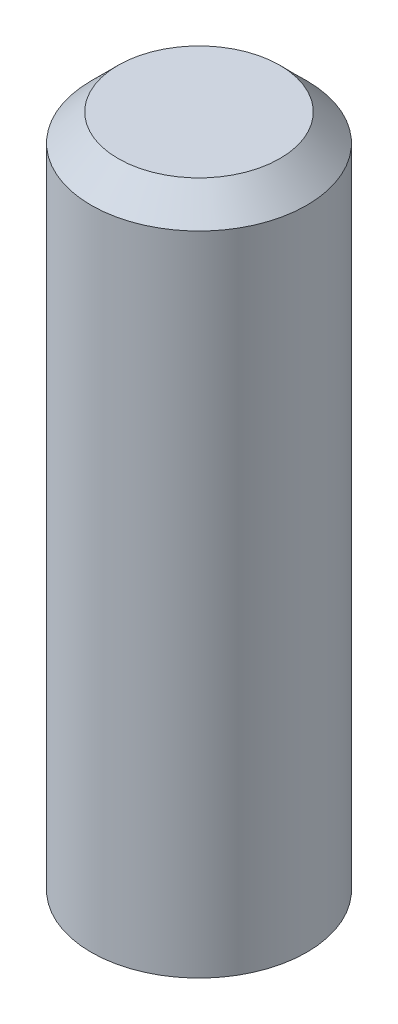
from build123d import *

# Parameters (mm, degrees)
SKETCH1_R             = 4
BOSS_EXTRUDE1_DEPTH   = 25
CHAMFER1_SIZE         = 1
M5_TAPPED_HOLE1_D     = 4.2
M5_TAPPED_HOLE1_DEPTH = 6
M5_TAPPED_HOLE1_TIP   = 1.2618073


with BuildPart() as part:
    # Sketch1 → Boss-Extrude1 (new body)
    with BuildSketch(Plane(origin=(0, 0, 0), x_dir=(1, 0, 0), z_dir=(0, 1, 0))):
        Circle(SKETCH1_R)
    extrude(amount=BOSS_EXTRUDE1_DEPTH)

    # Chamfer1
    chamfer1_edges = [part.edges().sort_by_distance(p)[0] for p in [
        (-4, 25, 0),
    ]]
    chamfer(chamfer1_edges, length=CHAMFER1_SIZE)

    # M5 Tapped Hole1
    with Locations(Plane.XZ):
        with Locations((0, 0)):
            Hole(M5_TAPPED_HOLE1_D / 2, depth=M5_TAPPED_HOLE1_DEPTH)
            with Locations((0, 0, -(M5_TAPPED_HOLE1_DEPTH + M5_TAPPED_HOLE1_TIP / 2))):  # 118° drill point
                Cone(0, M5_TAPPED_HOLE1_D / 2, M5_TAPPED_HOLE1_TIP, mode=Mode.SUBTRACT)


solid = part.part
